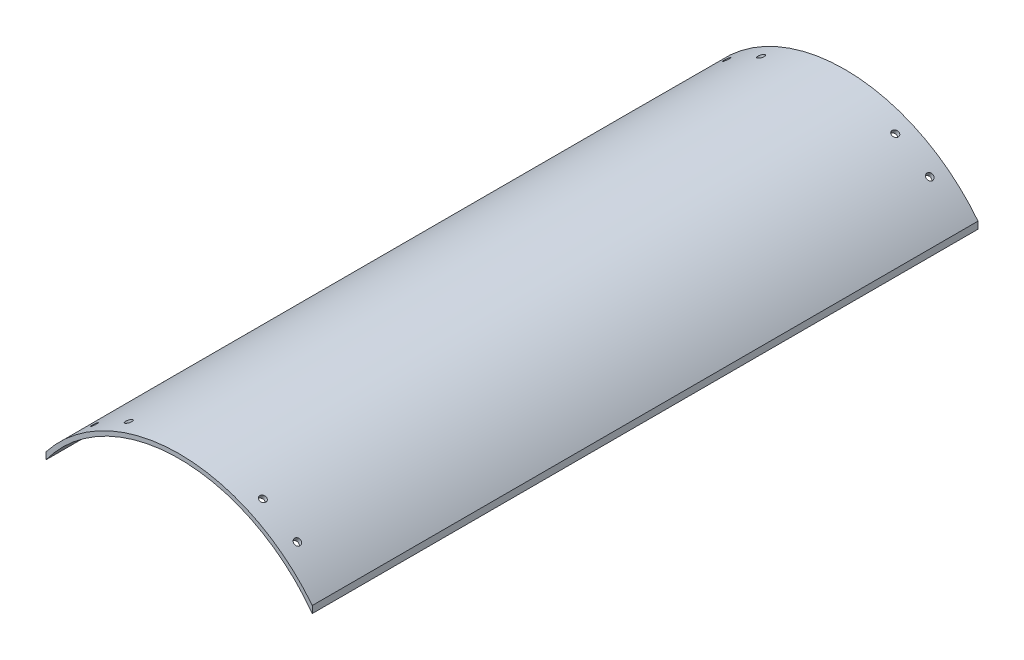
from build123d import *

# Parameters (mm, degrees)
BOSS_EXTRUDE1_DEPTH = 200
SKETCH5_R           = 1.5
CUT_EXTRUDE2_DEPTH  = 9
SKETCH6_R           = 1
CUT_EXTRUDE3_DEPTH  = 7
SKETCH7_R           = 1
CUT_EXTRUDE4_DEPTH  = 7


with BuildPart() as part:
    # Sketch1 → Boss-Extrude1 (new body)
    with BuildSketch(Plane.XY):
        with BuildLine():
            Line((-40, 31.315172042), (-40, 29.209945224))
            ThreePointArc((-40, 29.209945224), (0, 49.53), (40, 29.209945224))
            Line((40, 29.209945224), (40, 31.315172042))
            ThreePointArc((40, 31.315172042), (0, 50.8), (-40, 31.315172042))
        make_face()
    extrude(amount=BOSS_EXTRUDE1_DEPTH)

    # Sketch5 → Cut-Extrude2 (cut)
    with BuildSketch(Plane(origin=(-693.222728567, -633.307165687, 0), x_dir=(0.698885638, 0.715233434, 0), z_dir=(-0.715233434, 0.698885638, 0))):
        with Locations((937.445867756, -30)):
            Circle(SKETCH5_R)
        with Locations((937.445867756, -55.4)):
            Circle(SKETCH5_R)
        with Locations((937.445867756, -144.6)):
            Circle(SKETCH5_R)
        with Locations((937.445867756, -170)):
            Circle(SKETCH5_R)
    extrude(amount=-CUT_EXTRUDE2_DEPTH, mode=Mode.SUBTRACT)

    # Sketch6 → Cut-Extrude3 (cut)
    with BuildSketch(Plane(origin=(24.145050499, 41.582102129, -52.4), x_dir=(0, 0, 1), z_dir=(-0.502144913, -0.864783491, 0))):
        with Locations((247.4, 6)):
            Circle(SKETCH6_R)
        with Locations((247.4, -6)):
            Circle(SKETCH6_R)
        with Locations((57.4, 6)):
            Circle(SKETCH6_R)
        with Locations((57.4, -6)):
            Circle(SKETCH6_R)
    extrude(amount=-CUT_EXTRUDE3_DEPTH, mode=Mode.SUBTRACT)

    # Sketch7 → Cut-Extrude4 (cut)
    with BuildSketch(Plane(origin=(-24.145050502, 41.582102128, -52.4), x_dir=(0.864783491, 0.502144913, 0), z_dir=(0.502144913, -0.864783491, 0))):
        with Locations((-6, 247.4)):
            Circle(SKETCH7_R)
        with Locations((6, 247.4)):
            Circle(SKETCH7_R)
        with Locations((-6, 57.4)):
            Circle(SKETCH7_R)
        with Locations((6, 57.4)):
            Circle(SKETCH7_R)
    extrude(amount=-CUT_EXTRUDE4_DEPTH, mode=Mode.SUBTRACT)


solid = part.part
